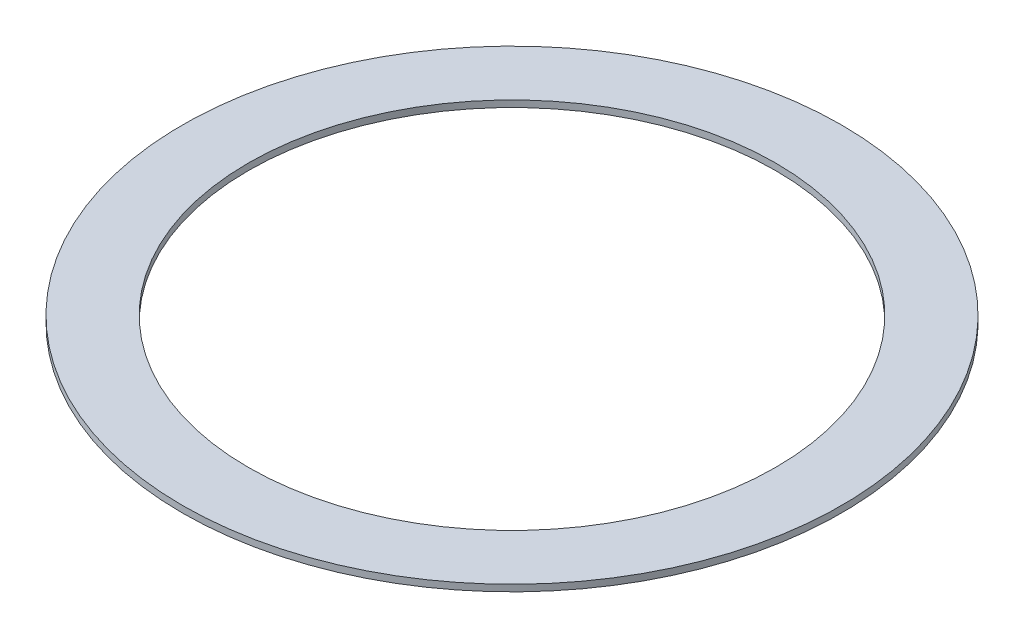
from build123d import *

# Parameters (mm, degrees)
CROQUIS1_R              = 100
CROQUIS1_R_2            = 80
SALIENTE_EXTRUIR1_DEPTH = 2


with BuildPart() as part:
    # Croquis1 → Saliente-Extruir1 (new body)
    with BuildSketch(Plane(origin=(0, 0, 0), x_dir=(1, 0, 0), z_dir=(0, 1, 0))):
        Circle(CROQUIS1_R)
        Circle(CROQUIS1_R_2, mode=Mode.SUBTRACT)
    extrude(amount=SALIENTE_EXTRUIR1_DEPTH)


solid = part.part
